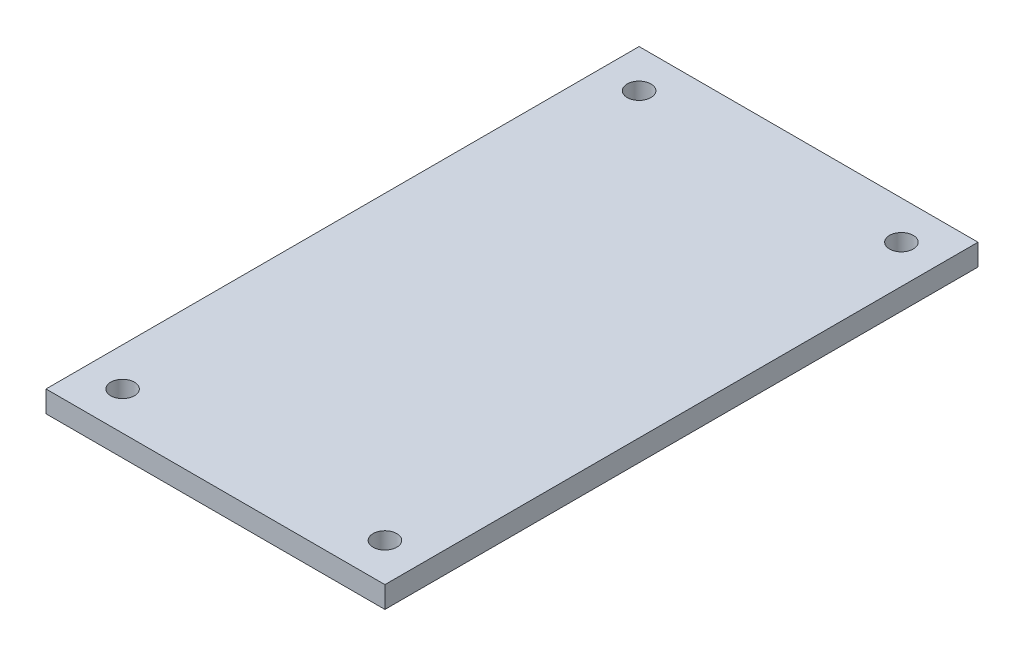
from build123d import *

# Parameters (mm, degrees)
SKETCH1_W           = 100
SKETCH1_H           = 175
SKETCH1_R           = 3.5
BOSS_EXTRUDE1_DEPTH = 6.35


with BuildPart() as part:
    # Sketch1 → Boss-Extrude1 (new body)
    with BuildSketch(Plane(origin=(0, 0, 0), x_dir=(1, 0, 0), z_dir=(0, 1, 0))):
        with Locations((-50, -87.5)):
            Rectangle(SKETCH1_W, SKETCH1_H)
        with Locations((-88.7, -163.7)):
            Circle(SKETCH1_R, mode=Mode.SUBTRACT)
        with Locations((-11.3, -163.7)):
            Circle(SKETCH1_R, mode=Mode.SUBTRACT)
        with Locations((-11.3, -11.3)):
            Circle(SKETCH1_R, mode=Mode.SUBTRACT)
        with Locations((-88.7, -11.3)):
            Circle(SKETCH1_R, mode=Mode.SUBTRACT)
    extrude(amount=BOSS_EXTRUDE1_DEPTH)


solid = part.part
